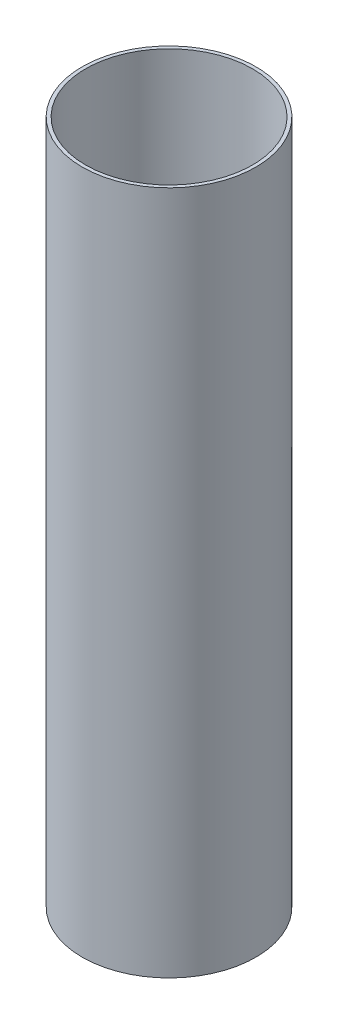
from build123d import *

# Parameters (mm, degrees)
SKETCH1_R           = 39.6748
SKETCH1_R_2         = 38.1
BOSS_EXTRUDE1_DEPTH = 156.21


with BuildPart() as part:
    # Sketch1 → Boss-Extrude1 (new body, symmetric)
    with BuildSketch(Plane(origin=(0, 0, 0), x_dir=(1, 0, 0), z_dir=(0, 1, 0))):
        Circle(SKETCH1_R)
        Circle(SKETCH1_R_2, mode=Mode.SUBTRACT)
    extrude(amount=BOSS_EXTRUDE1_DEPTH, both=True)


solid = part.part
